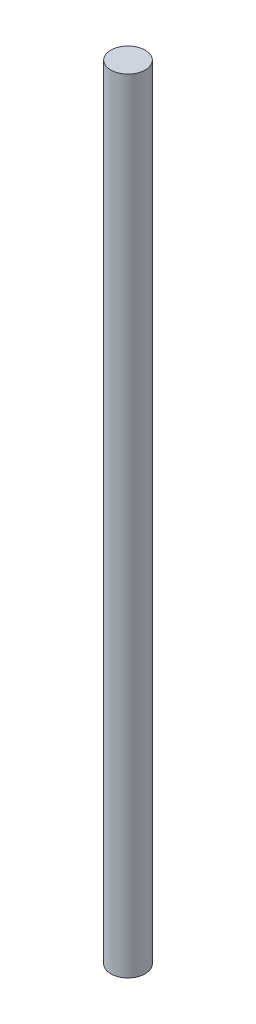
from build123d import *

# Parameters (mm, degrees)
SKETCH1_R           = 1.8415
BOSS_EXTRUDE1_DEPTH = 83.693


with BuildPart() as part:
    # Sketch1 → Boss-Extrude1 (new body)
    with BuildSketch(Plane(origin=(0, 0, 0), x_dir=(1, 0, 0), z_dir=(0, 1, 0))):
        Circle(SKETCH1_R)
    extrude(amount=BOSS_EXTRUDE1_DEPTH)


solid = part.part
